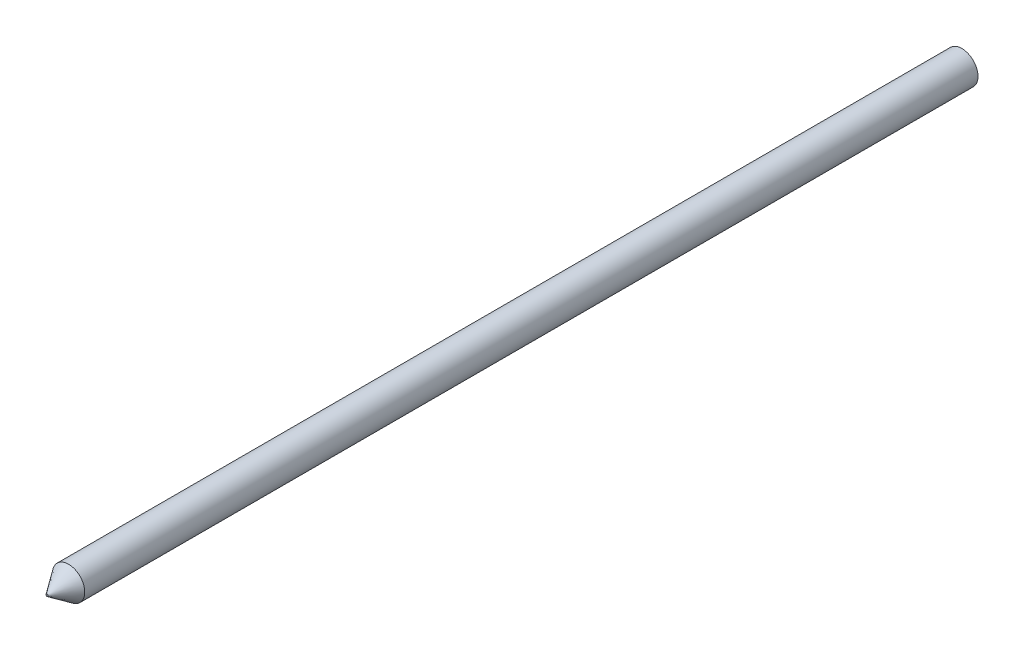
from build123d import *

# Parameters (mm, degrees)
SKICA1_R        = 3
VYSUNOUT1_DEPTH = 170
ZKOSIT1_SIZE    = 4
ZKOSIT1_SIZE2   = 2.800830153


with BuildPart() as part:
    # Skica1 → Vysunout1 (new body)
    with BuildSketch(Plane.XY):
        Circle(SKICA1_R)
    extrude(amount=VYSUNOUT1_DEPTH)

    # Zkosit1
    zkosit1_edges = [part.edges().sort_by_distance(p)[0] for p in [
        (-3, 0, 170),
    ]]
    zkosit1_side = [part.faces().sort_by_distance(p)[0] for p in [
        (-3, 0, 85),
    ]]
    chamfer(zkosit1_edges, length=ZKOSIT1_SIZE, length2=ZKOSIT1_SIZE2, reference=zkosit1_side[0])


solid = part.part
